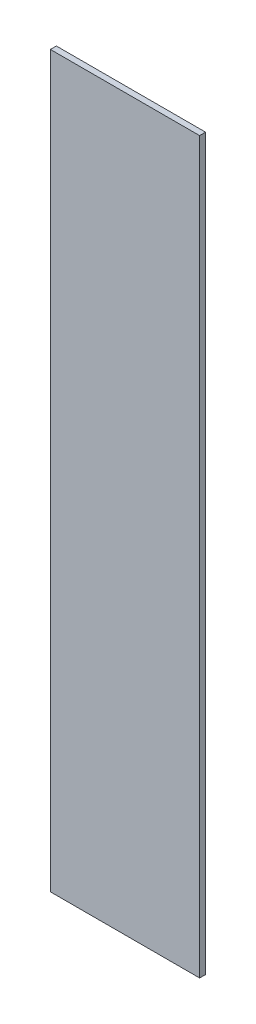
from build123d import *

# Parameters (mm, degrees)
SKETCH1_W           = 450
SKETCH1_H           = 2200
BOSS_EXTRUDE1_DEPTH = 18


with BuildPart() as part:
    # Sketch1 → Boss-Extrude1 (new body)
    with BuildSketch(Plane.XY):
        with Locations((225, 1100)):
            Rectangle(SKETCH1_W, SKETCH1_H)
    extrude(amount=BOSS_EXTRUDE1_DEPTH)


solid = part.part
